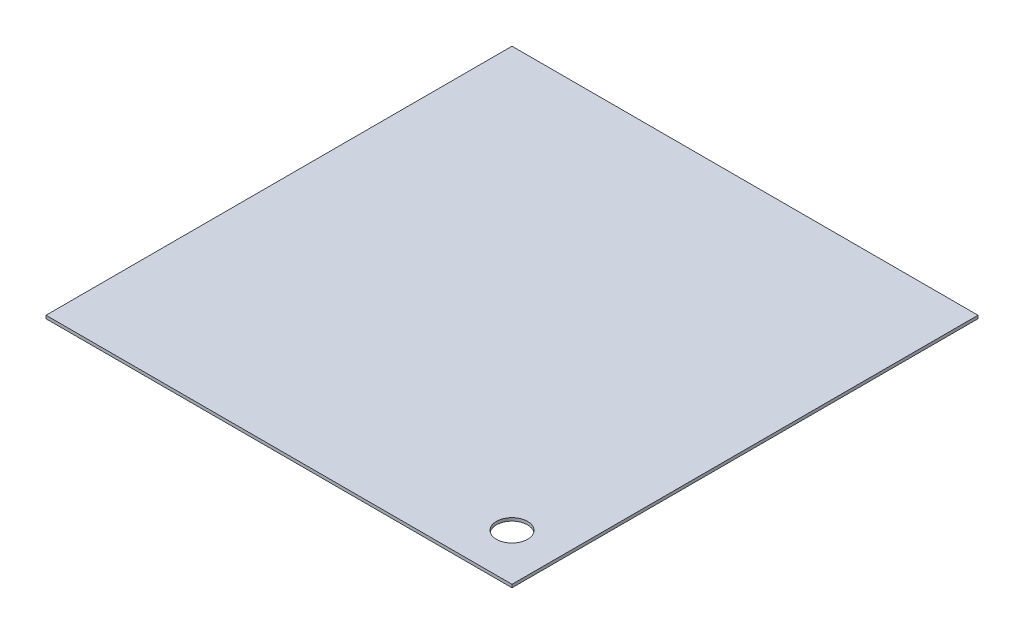
from build123d import *

# Parameters (mm, degrees)
SKETCH1_W           = 380.0856
SKETCH1_H           = 380.0856
BOSS_EXTRUDE1_DEPTH = 2.5
SKETCH2_R           = 12.7
CUT_EXTRUDE1_DEPTH  = 3.5


with BuildPart() as part:
    # Sketch1 → Boss-Extrude1 (new body)
    with BuildSketch(Plane(origin=(0, 0, 0), x_dir=(1, 0, 0), z_dir=(0, 1, 0))):
        Rectangle(SKETCH1_W, SKETCH1_H)
    extrude(amount=BOSS_EXTRUDE1_DEPTH)

    # Sketch2 → Cut-Extrude1 (cut, through all)
    with BuildSketch(Plane(origin=(0, 2.5, 0), x_dir=(1, 0, 0), z_dir=(0, 1, 0))):
        with Locations((151.9428, -151.9428)):
            Circle(SKETCH2_R)
    extrude(amount=-CUT_EXTRUDE1_DEPTH, mode=Mode.SUBTRACT)


solid = part.part
